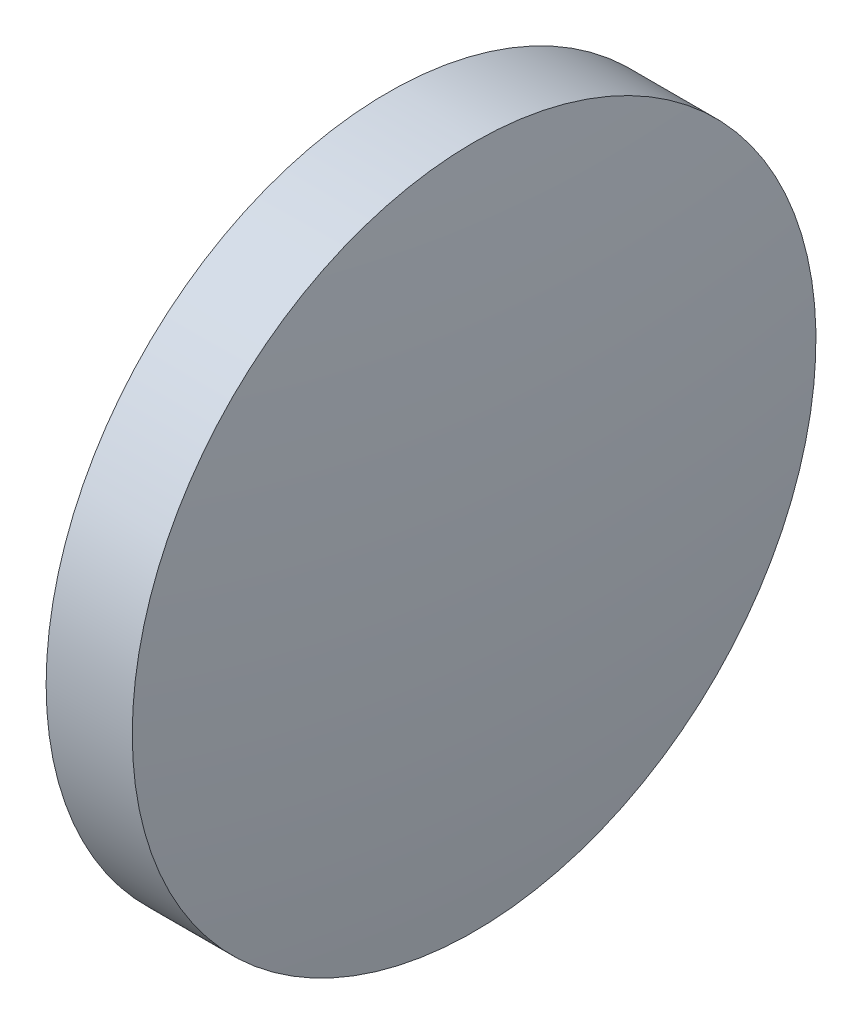
from build123d import *


with BuildPart() as part:
    # 草图1 → 旋转1 (revolve)
    with BuildSketch(Plane.XY):
        with BuildLine():
            Line((211.144485706, 4.506726094), (211.144485706, 10.856726094))
            Line((211.144485706, 10.856726094), (212.744485706, 10.856726094))
            ThreePointArc((212.744485706, 10.856726094), (213.044386702, 7.68801907), (213.144485706, 4.506726094))
            Line((213.144485706, 4.506726094), (211.144485706, 4.506726094))
        make_face()
    revolve(axis=Axis((208.275376688, 4.506726094, 0), (1, 0, 0)))


solid = part.part
